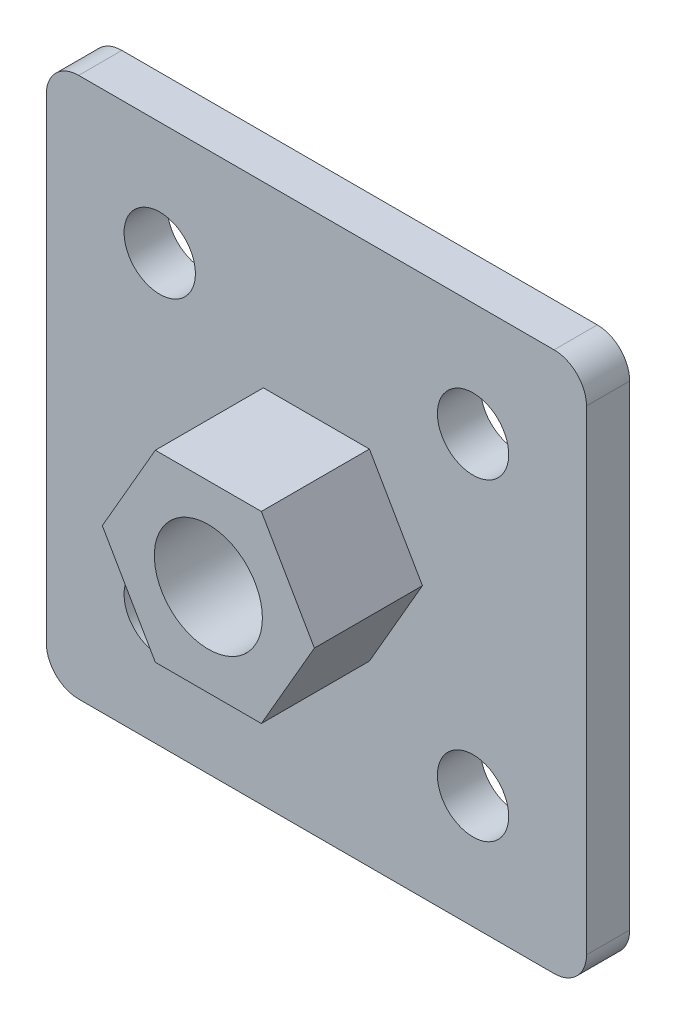
from build123d import *

# Parameters (mm, degrees)
SKETCH_1_W         = 50
SKETCH_1_H         = 50
EXTRUDE_1_DEPTH    = 4
HOLE_WIZARD_M101_D = 11
FILLET_1_R         = 3
HOLE_WIZARD_M61_D  = 6.6
SKETCH_6_R         = 5
EXTRUDE_2_DEPTH    = 10


with BuildPart() as part:
    # Эскиз1 → Бобышка-Вытянуть1 (new body)
    with BuildSketch(Plane.XY):
        Rectangle(SKETCH_1_W, SKETCH_1_H)
    extrude(amount=EXTRUDE_1_DEPTH)

    # Отверстие с зазором M101 (through all)
    with Locations(Plane.XY.offset(4)):
        with Locations((0, 0)):
            Hole(HOLE_WIZARD_M101_D / 2)

    # Скругление1
    fillet_1_edges = [part.edges().sort_by_distance(p)[0] for p in [
        (25, -25, 2),
        (-25, -25, 2),
        (-25, 25, 2),
        (25, 25, 2),
    ]]
    fillet(fillet_1_edges, radius=FILLET_1_R)

    # Отверстие с зазором M61 (through all)
    with Locations(Plane(origin=(0, 0, 0), x_dir=(-1, 0, 0), z_dir=(0, 0, -1))):
        with Locations((-14.5, 14.5), (0, 0), (14.5, 14.5), (-14.5, -14.5), (14.5, -14.5)):
            Hole(HOLE_WIZARD_M61_D / 2)

    # Эскиз6 → Бобышка-Вытянуть2 (add)
    with BuildSketch(Plane.XY.offset(4)):
        Polygon((4.907477288, -8.5), (9.814954576, 0), (4.907477288, 8.5), (-4.907477288, 8.5), (-9.814954576, 0), (-4.907477288, -8.5), align=None)
        Circle(SKETCH_6_R, mode=Mode.SUBTRACT)
    extrude(amount=EXTRUDE_2_DEPTH)


solid = part.part
